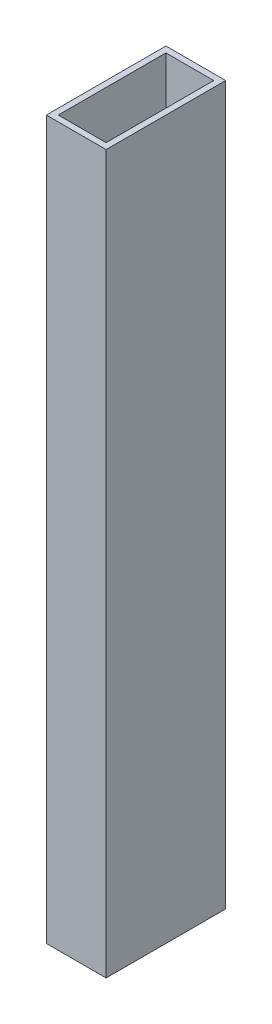
from build123d import *

# Parameters (mm, degrees)
SKETCH1_W           = 10
SKETCH1_H           = 20
SKETCH1_W_2         = 8
SKETCH1_H_2         = 18
BOSS_EXTRUDE1_DEPTH = 120


with BuildPart() as part:
    # Sketch1 → Boss-Extrude1 (new body)
    with BuildSketch(Plane(origin=(0, 0, 0), x_dir=(1, 0, 0), z_dir=(0, 1, 0))):
        Rectangle(SKETCH1_W, SKETCH1_H)
        Rectangle(SKETCH1_W_2, SKETCH1_H_2, mode=Mode.SUBTRACT)
    extrude(amount=BOSS_EXTRUDE1_DEPTH)


solid = part.part
